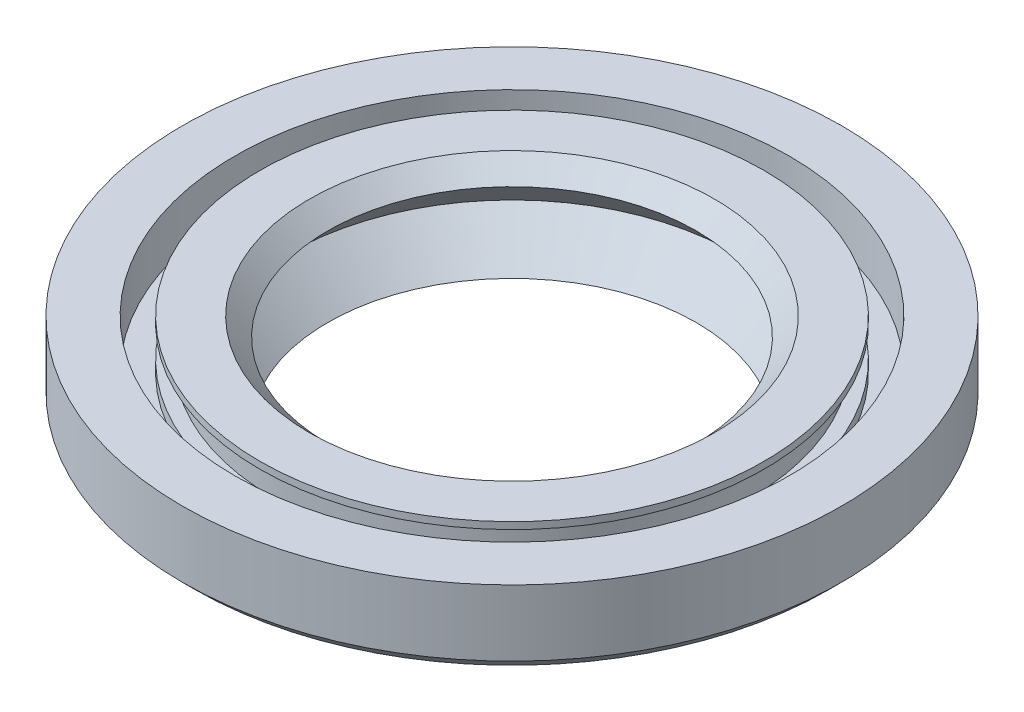
from build123d import *


with BuildPart() as part:
    # Эскиз1 → Повернуть1 (revolve)
    with BuildSketch(Plane.XY):
        Polygon((11.525952606, -1.221276852), (9.5, 0.804675754), (10.445620692, 1.750296446), (13, 1.750296446), (13, 1.395888621), (12.316457293, 1.395888621), (12.316457293, -0.208300549), (13, -0.208300549), (13, -0.785082607), (14.294407296, -0.785082607), (14.294407296, 1.750296446), (17, 1.750296446), (17, -1.654414722), (16.3705936, -2.283821122), (14.071003585, -2.283821122), (11.999272747, -3.593083063), (9.5, -3.293199519), align=None)
    revolve(axis=Axis((0, 17.208784833, 0), (0, -1, 0)))


solid = part.part
